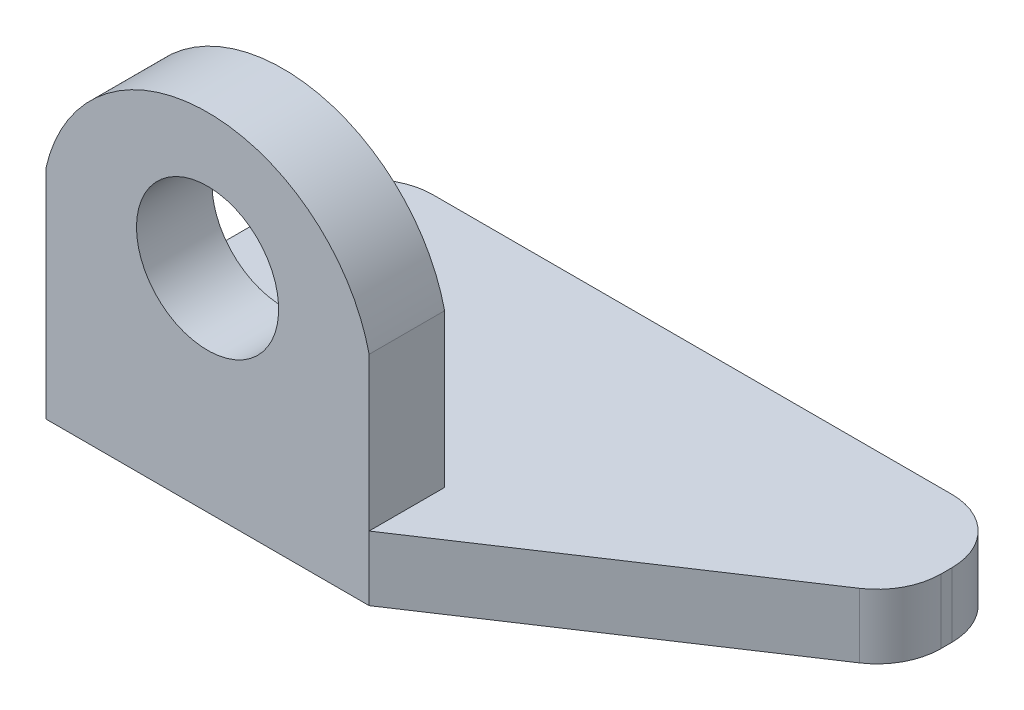
from build123d import *

# Parameters (mm, degrees)
BOSS_EXTRUDE1_DEPTH = 10.16
SKETCH3_W           = 50.8
SKETCH3_H           = 24.064486013
BOSS_EXTRUDE2_DEPTH = 11.8629
SKETCH4_R           = 11.176966962
CUT_EXTRUDE2_DEPTH  = 12.862900188
FILLET1_R           = 10
FILLET2_R           = 10
FILLET3_R           = 10


with BuildPart() as part:
    # Sketch1 → Boss-Extrude1 (new body)
    with BuildSketch(Plane(origin=(0, 0, 0), x_dir=(1, 0, 0), z_dir=(0, 1, 0))):
        Polygon((38.154070096, 38.937099812), (-63.445929904, 38.937099812), (-63.445929904, -11.862900188), (-12.645929904, -11.862900188), (38.154070096, 21.8411914), align=None)
    extrude(amount=BOSS_EXTRUDE1_DEPTH)

    # Sketch3 → Boss-Extrude2 (add)
    with BuildSketch(Plane.XY):
        with BuildLine():
            ThreePointArc((-63.445929904, 34.224486013), (-38.045929904, 54.474648718), (-12.645929904, 34.224486013))
            Line((-12.645929904, 34.224486013), (-63.445929904, 34.224486013))
        make_face()
        with Locations((-38.045929904, 22.192243007)):
            Rectangle(SKETCH3_W, SKETCH3_H)
    extrude(amount=BOSS_EXTRUDE2_DEPTH)

    # Sketch4 → Cut-Extrude2 (cut, through all)
    with BuildSketch(Plane(origin=(0, 0, 0), x_dir=(-1, 0, 0), z_dir=(0, 0, -1))):
        with Locations((38.045929904, 33.23792349)):
            Circle(SKETCH4_R)
    extrude(amount=-CUT_EXTRUDE2_DEPTH, mode=Mode.SUBTRACT)

    # Fillet1
    fillet1_edges = [part.edges().sort_by_distance(p)[0] for p in [
        (38.154070096, 5.08, -38.937099812),
    ]]
    fillet(fillet1_edges, radius=FILLET1_R)

    # Fillet2
    fillet2_edges = [part.edges().sort_by_distance(p)[0] for p in [
        (38.154070096, 5.08, -21.8411914),
    ]]
    fillet(fillet2_edges, radius=FILLET2_R)

    # Fillet3
    fillet3_edges = [part.edges().sort_by_distance(p)[0] for p in [
        (-63.445929904, 5.08, -38.937099812),
    ]]
    fillet(fillet3_edges, radius=FILLET3_R)


solid = part.part
